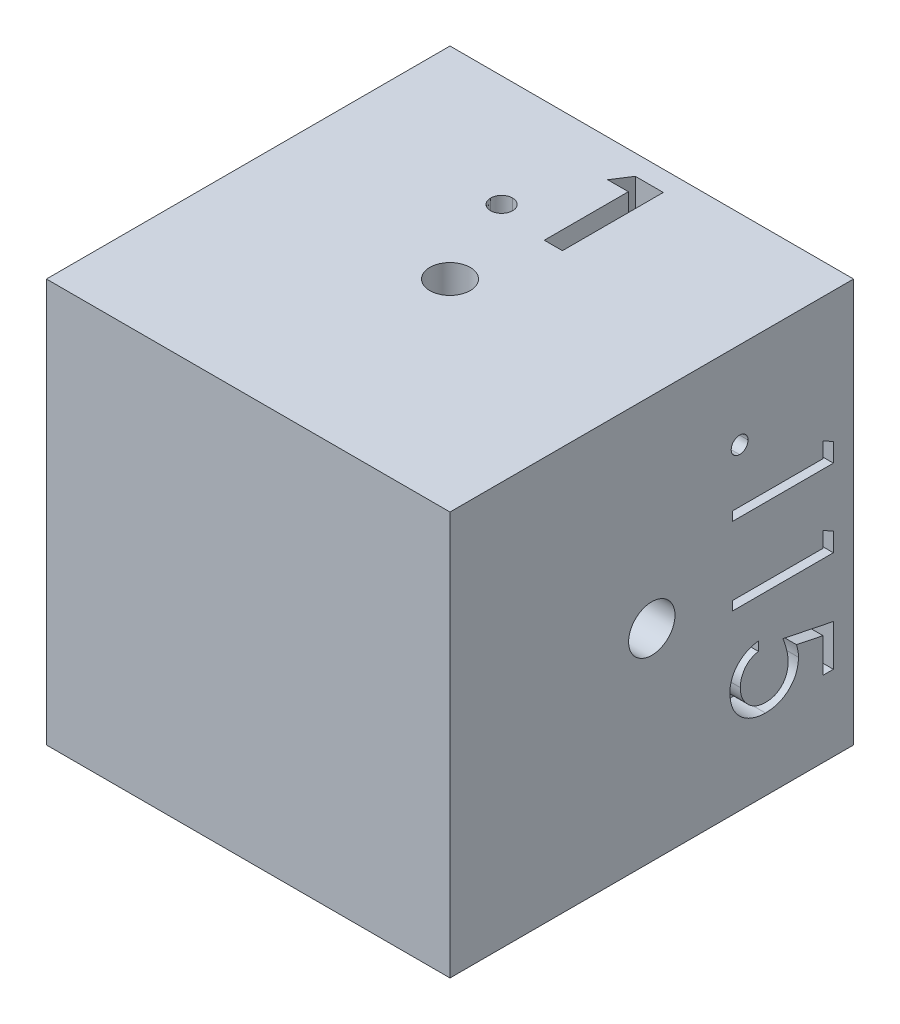
from build123d import *

# Parameters (mm, degrees)
SKETCH1_W           = 25.4
SKETCH1_H           = 25.4
BOSS_EXTRUDE1_DEPTH = 12.7
SKETCH2_R           = 1.27
CUT_EXTRUDE1_DEPTH  = 12.7
SKETCH4_R           = 1.4605
CUT_EXTRUDE2_DEPTH  = 12.7
SKETCH5_R           = 1.524
CUT_EXTRUDE3_DEPTH  = 12.7
SKETCH6_R           = 1.5875
CUT_EXTRUDE4_DEPTH  = 12.7
CUT_EXTRUDE5_DEPTH  = 1.905
CUT_EXTRUDE6_DEPTH  = 1.905
CUT_EXTRUDE7_DEPTH  = 1.905
CUT_EXTRUDE8_DEPTH  = 1.905


with BuildPart() as part:
    # Sketch1 → Boss-Extrude1 (new body, symmetric)
    with BuildSketch(Plane(origin=(0, 0, 0), x_dir=(1, 0, 0), z_dir=(0, 1, 0))):
        Rectangle(SKETCH1_W, SKETCH1_H)
    extrude(amount=BOSS_EXTRUDE1_DEPTH, both=True)

    # Sketch2 → Cut-Extrude1 (cut)
    with BuildSketch(Plane(origin=(0, 12.7, 0), x_dir=(1, 0, 0), z_dir=(0, 1, 0))):
        Circle(SKETCH2_R)
    extrude(amount=-CUT_EXTRUDE1_DEPTH, mode=Mode.SUBTRACT)

    # Sketch4 → Cut-Extrude2 (cut)
    with BuildSketch(Plane(origin=(12.7, 0, 0), x_dir=(0, 0, -1), z_dir=(1, 0, 0))):
        Circle(SKETCH4_R)
    extrude(amount=-CUT_EXTRUDE2_DEPTH, mode=Mode.SUBTRACT)

    # Sketch5 → Cut-Extrude3 (cut)
    with BuildSketch(Plane.XZ.offset(12.7)):
        Circle(SKETCH5_R)
    extrude(amount=-CUT_EXTRUDE3_DEPTH, mode=Mode.SUBTRACT)

    # Sketch6 → Cut-Extrude4 (cut)
    with BuildSketch(Plane(origin=(-12.7, 0, 0), x_dir=(0, 0, -1), z_dir=(1, 0, 0))):
        Circle(SKETCH6_R)
    extrude(amount=CUT_EXTRUDE4_DEPTH, mode=Mode.SUBTRACT)

    # Sketch7 → Cut-Extrude5 (cut)
    with BuildSketch(Plane(origin=(0, 12.7, 0), x_dir=(1, 0, 0), z_dir=(0, 1, 0))):
        with BuildLine():
            add(Edge.make_bspline(
                [(-2.442307692, 6.382564103), (-2.396297595, 6.380041479), (-2.30571166, 6.37507487), (-2.174827334, 6.338009585), (-2.056703477, 6.271416521), (-1.951084965, 6.184557409), (-1.861776611, 6.080054302), (-1.797226553, 5.960881284), (-1.757029613, 5.830501274), (-1.752591842, 5.739630345), (-1.750320513, 5.693120994)],
                knots=[0, 0, 0, 0, 0.000137967, 0.000271634, 0.000403712, 0.000541989, 0.000680103, 0.000813297, 0.000946101, 0.001085336, 0.001085336, 0.001085336, 0.001085336], degree=3))
            add(Edge.make_bspline(
                [(-1.750320513, 5.693120994), (-1.752576963, 5.646604173), (-1.756985662, 5.555718649), (-1.797504712, 5.425084584), (-1.861680153, 5.304932073), (-1.951092131, 5.199309146), (-2.056266074, 5.110813094), (-2.175098922, 5.044834114), (-2.305462327, 5.00566621), (-2.39625371, 5.00097126), (-2.442307692, 4.998589744)],
                knots=[0, 0, 0, 0, 0.000139234, 0.000272039, 0.000406351, 0.00054544, 0.000684529, 0.000816606, 0.000950629, 0.001088597, 0.001088597, 0.001088597, 0.001088597], degree=3))
            add(Edge.make_bspline(
                [(-2.442307692, 4.998589744), (-2.488372587, 5.000951894), (-2.579185482, 5.005608667), (-2.709751529, 5.045164261), (-2.829461693, 5.110372593), (-2.934662062, 5.199416492), (-3.024473492, 5.304558054), (-3.086824366, 5.425463687), (-3.12772084, 5.555669398), (-3.132069269, 5.6465875), (-3.134294872, 5.693120994)],
                knots=[0, 0, 0, 0, 0.000137967, 0.000271991, 0.000405184, 0.000544273, 0.000683362, 0.000817077, 0.000949881, 0.001089116, 0.001089116, 0.001089116, 0.001089116], degree=3))
            add(Edge.make_bspline(
                [(-3.134294872, 5.693120994), (-3.132054586, 5.739647308), (-3.127677469, 5.830551382), (-3.087101733, 5.960497815), (-3.024373564, 6.080430354), (-2.934669552, 6.184449841), (-2.829022037, 6.271853583), (-2.71002464, 6.337683962), (-2.578936276, 6.375132839), (-2.488328754, 6.380061005), (-2.442307692, 6.382564103)],
                knots=[0, 0, 0, 0, 0.000139234, 0.000272039, 0.000404629, 0.000542743, 0.000681021, 0.000814215, 0.000947882, 0.001085849, 0.001085849, 0.001085849, 0.001085849], degree=3))
        make_face()
        Polygon((0.232782452, 11.43), (1.994551282, 11.43), (1.994551282, 5.08), (0.854807692, 5.08), (0.854807692, 10.371666667), (-0.44775641, 10.371666667), align=None)
    extrude(amount=-CUT_EXTRUDE5_DEPTH, mode=Mode.SUBTRACT)

    # Sketch9 → Cut-Extrude6 (cut)
    with BuildSketch(Plane(origin=(12.7, 0, 0), x_dir=(0, 0, -1), z_dir=(1, 0, 0))):
        with BuildLine():
            add(Edge.make_bspline(
                [(6.056923077, 7.245512821), (6.054891267, 7.210127533), (6.050931558, 7.141166644), (6.021829667, 7.041309193), (5.972726399, 6.950057506), (5.905258007, 6.869277712), (5.824709926, 6.802139353), (5.733690044, 6.752471082), (5.633543092, 6.722035242), (5.563587428, 6.718273105), (5.52775641, 6.716346154)],
                knots=[0, 0, 0, 0, 0.000106068, 0.000206712, 0.000309148, 0.00041485, 0.000520551, 0.000621868, 0.000724091, 0.000831425, 0.000831425, 0.000831425, 0.000831425], degree=3))
            add(Edge.make_bspline(
                [(5.52775641, 6.716346154), (5.492786963, 6.718350083), (5.423708683, 6.722308623), (5.324319503, 6.752407893), (5.233239101, 6.802528231), (5.151595984, 6.868819458), (5.083983162, 6.950077164), (5.035317742, 7.041529807), (5.004179507, 7.140927253), (5.000483127, 7.210087249), (4.998589744, 7.245512821)],
                knots=[0, 0, 0, 0, 0.000104802, 0.000207025, 0.000308342, 0.000415026, 0.000520727, 0.000623164, 0.000724168, 0.000830237, 0.000830237, 0.000830237, 0.000830237], degree=3))
            add(Edge.make_bspline(
                [(4.998589744, 7.245512821), (5.000554208, 7.280912884), (5.004411918, 7.350429642), (5.034695939, 7.450199496), (5.084449722, 7.54109856), (5.151471016, 7.62237209), (5.233662038, 7.68811272), (5.323699421, 7.74054204), (5.423995789, 7.768232771), (5.492843512, 7.772510326), (5.52775641, 7.774679487)],
                knots=[0, 0, 0, 0, 0.000106068, 0.000208291, 0.000309608, 0.000415309, 0.000521993, 0.000623923, 0.000725789, 0.000830591, 0.000830591, 0.000830591, 0.000830591], degree=3))
            add(Edge.make_bspline(
                [(5.52775641, 7.774679487), (5.563528859, 7.772581422), (5.633251269, 7.768492182), (5.734309873, 7.740477824), (5.824291021, 7.688508785), (5.905381725, 7.621912749), (5.972261337, 7.541118533), (6.022442049, 7.450413936), (6.050702586, 7.350194375), (6.054821832, 7.280873634), (6.056923077, 7.245512821)],
                knots=[0, 0, 0, 0, 0.000107334, 0.000209201, 0.00031113, 0.000416832, 0.000522533, 0.00062385, 0.000725716, 0.000831784, 0.000831784, 0.000831784, 0.000831784], degree=3))
        make_face()
        Polygon((11.43, 4.471203926), (11.43, 3.297115385), (5.08, 3.297115385), (5.08, 3.866987179), (10.778717949, 3.866987179), (10.778717949, 4.843910256), align=None)
        Polygon((11.43, -0.413411458), (11.43, -1.5875), (5.08, -1.5875), (5.08, -1.017628205), (10.778717949, -1.017628205), (10.778717949, -0.040705128), align=None)
        with BuildLine():
            Line((11.43, -7.9375), (10.778717949, -7.9375))
            Line((10.778717949, -7.9375), (10.778717949, -5.777584135))
            Line((10.778717949, -5.777584135), (9.108535657, -5.435406651))
            add(Edge.make_bspline(
                [(9.108535657, -5.435406651), (9.127096293, -5.502636594), (9.16305459, -5.632883977), (9.202979345, -5.825125439), (9.22704665, -6.007628436), (9.230332885, -6.126056608), (9.231923077, -6.183363381)],
                knots=[0, 0, 0, 0, 0.000209191, 0.000405274, 0.000588611, 0.000760505, 0.000760505, 0.000760505, 0.000760505], degree=3))
            add(Edge.make_bspline(
                [(9.231923077, -6.183363381), (9.230387906, -6.254272207), (9.227369377, -6.393696676), (9.198397587, -6.597696528), (9.152765869, -6.792416436), (9.089122448, -6.97752371), (9.007214214, -7.153417054), (8.906223075, -7.319114197), (8.786847577, -7.475554206), (8.650239492, -7.620669004), (8.499706458, -7.752112957), (8.33838207, -7.868138945), (8.166119588, -7.964635121), (7.983680744, -8.044023974), (7.79137165, -8.107011362), (7.587768837, -8.149049426), (7.374679093, -8.177010413), (7.228984395, -8.18013661), (7.154689503, -8.181730769)],
                knots=[0, 0, 0, 0, 0.000212616, 0.000418057, 0.000616755, 0.000811858, 0.001004205, 0.001197709, 0.001392845, 0.001593525, 0.001794559, 0.001991523, 0.00218859, 0.002385686, 0.002587623, 0.002794449, 0.003008552, 0.003231336, 0.003231336, 0.003231336, 0.003231336], degree=3))
            add(Edge.make_bspline(
                [(7.154689503, -8.181730769), (7.102941978, -8.180524295), (7.000146252, -8.178127652), (6.847485626, -8.165935831), (6.698052212, -8.142475611), (6.551848249, -8.110932885), (6.409069199, -8.070155009), (6.269766997, -8.020254344), (6.133512706, -7.961433762), (6.000297404, -7.895023931), (5.874227905, -7.818200065), (5.753358138, -7.737275088), (5.642136364, -7.647632488), (5.536502247, -7.553612314), (5.440604205, -7.451455087), (5.350338346, -7.344331604), (5.269625633, -7.229727944), (5.195388158, -7.109695939), (5.128918807, -6.984311278), (5.073471495, -6.852302589), (5.024871447, -6.716567806), (4.98534963, -6.57589714), (4.954686413, -6.430563112), (4.933805178, -6.280065254), (4.918612262, -6.125158737), (4.917660336, -6.020157145), (4.917179487, -5.967117388)],
                knots=[0, 0, 0, 0, 0.000155272, 0.000308445, 0.000459024, 0.000608725, 0.000756894, 0.000904154, 0.001052306, 0.00120192, 0.001350264, 0.001494918, 0.001637953, 0.001778454, 0.001918817, 0.002057905, 0.002198383, 0.002338884, 0.00248113, 0.002623604, 0.00276804, 0.002913414, 0.003061605, 0.003213255, 0.003369073, 0.003528123, 0.003528123, 0.003528123, 0.003528123], degree=3))
            add(Edge.make_bspline(
                [(4.917179487, -5.967117388), (4.918432974, -5.903845737), (4.920899063, -5.77936624), (4.946693892, -5.596992107), (4.983645571, -5.421528211), (5.039207691, -5.254363195), (5.108930064, -5.094086683), (5.196489179, -4.942832263), (5.297098586, -4.797626959), (5.41422965, -4.66241728), (5.5434557, -4.537181012), (5.682187687, -4.423352123), (5.830977231, -4.323524869), (5.988557634, -4.237291863), (6.155200039, -4.163842599), (6.331403101, -4.106114027), (6.516280415, -4.059528098), (6.643558707, -4.039818482), (6.708205128, -4.029807692)],
                knots=[0, 0, 0, 0, 0.000189687, 0.000373186, 0.000551585, 0.000726969, 0.000900684, 0.001075027, 0.001250411, 0.001429913, 0.001610725, 0.001789725, 0.001967538, 0.002147431, 0.002327992, 0.002513029, 0.002703073, 0.002899231, 0.002899231, 0.002899231, 0.002899231], degree=3))
            Line((6.708205128, -4.029807692), (6.708205128, -4.599679487))
            add(Edge.make_bspline(
                [(6.708205128, -4.599679487), (6.64764493, -4.613692474), (6.531244866, -4.640626212), (6.367797746, -4.699899793), (6.221595909, -4.771925897), (6.092501332, -4.859521151), (5.979336183, -4.961898746), (5.87761919, -5.077883765), (5.787069571, -5.209128567), (5.711106198, -5.354914487), (5.646416187, -5.50880895), (5.603317623, -5.669852892), (5.573019052, -5.83369212), (5.569985783, -5.944505555), (5.568461538, -6.000190304)],
                knots=[0, 0, 0, 0, 0.000186343, 0.000358162, 0.000520291, 0.000674118, 0.000824546, 0.000976877, 0.001136009, 0.001301598, 0.001469314, 0.001635659, 0.001800867, 0.001967742, 0.001967742, 0.001967742, 0.001967742], degree=3))
            add(Edge.make_bspline(
                [(5.568461538, -6.000190304), (5.569950664, -6.054543482), (5.572882765, -6.161565334), (5.595450687, -6.319065993), (5.630207995, -6.471126493), (5.682223303, -6.616246412), (5.745441578, -6.756965205), (5.826567501, -6.889723331), (5.919930677, -7.018361408), (6.026894849, -7.138881022), (6.144768438, -7.249261166), (6.27082028, -7.346790128), (6.405289416, -7.428028243), (6.54584785, -7.496488697), (6.69403609, -7.548473968), (6.849159651, -7.585559748), (7.011601686, -7.607336726), (7.122398862, -7.610332439), (7.178858173, -7.611858974)],
                knots=[0, 0, 0, 0, 0.000162999, 0.000320947, 0.000476453, 0.000630132, 0.000782676, 0.000938437, 0.001095928, 0.001259031, 0.001421025, 0.001579785, 0.001736204, 0.001891522, 0.002048024, 0.002206299, 0.002369289, 0.002538641, 0.002538641, 0.002538641, 0.002538641], degree=3))
            add(Edge.make_bspline(
                [(7.178858173, -7.611858974), (7.229826301, -7.610856727), (7.329646331, -7.608893846), (7.475041678, -7.587081418), (7.613611912, -7.556525591), (7.744117841, -7.509611018), (7.868470538, -7.45164408), (7.984008401, -7.378101855), (8.093699797, -7.294035516), (8.193088559, -7.195570581), (8.285438896, -7.088198755), (8.364049623, -6.969427574), (8.430213096, -6.841966119), (8.487302962, -6.70728962), (8.528307751, -6.562211228), (8.559092179, -6.409599403), (8.576900097, -6.247807437), (8.579370946, -6.13718918), (8.580641026, -6.080328526)],
                knots=[0, 0, 0, 0, 0.000152777, 0.00029921, 0.000440222, 0.000577814, 0.000714373, 0.000850961, 0.000987851, 0.001128179, 0.001269879, 0.001412057, 0.001554303, 0.001700294, 0.001850038, 0.002005705, 0.002166968, 0.002337539, 0.002337539, 0.002337539, 0.002337539], degree=3))
            add(Edge.make_bspline(
                [(8.580641026, -6.080328526), (8.579623437, -6.030681463), (8.577540275, -5.929046217), (8.56114622, -5.772782201), (8.535925543, -5.609286755), (8.4995745, -5.437925138), (8.454060491, -5.259167622), (8.397219201, -5.072716931), (8.331745202, -4.87856856), (8.280961339, -4.747892805), (8.255, -4.681089744)],
                knots=[0, 0, 0, 0, 0.000148915, 0.000304852, 0.000470905, 0.000645039, 0.00083015, 0.001024118, 0.001229672, 0.001444658, 0.001444658, 0.001444658, 0.001444658], degree=3))
            Line((8.255, -4.681089744), (11.43, -5.332371795))
            Line((11.43, -5.332371795), (11.43, -7.9375))
        make_face()
    extrude(amount=-CUT_EXTRUDE6_DEPTH, mode=Mode.SUBTRACT)

    # Sketch10 → Cut-Extrude7 (cut)
    with BuildSketch(Plane(origin=(0, -12.7, 0), x_dir=(-1, 0, 0), z_dir=(0, -1, 0))):
        with BuildLine():
            add(Edge.make_bspline(
                [(-4.803205128, 6.056923077), (-4.767844315, 6.054821832), (-4.698523574, 6.050702586), (-4.598304012, 6.022442049), (-4.507599415, 5.972261337), (-4.4268052, 5.905381725), (-4.360209164, 5.824291021), (-4.308240125, 5.734309873), (-4.280225766, 5.633251269), (-4.276136526, 5.563528859), (-4.274038462, 5.52775641)],
                knots=[0, 0, 0, 0, 0.000106068, 0.000207934, 0.000309251, 0.000414952, 0.000520654, 0.000622584, 0.00072445, 0.000831784, 0.000831784, 0.000831784, 0.000831784], degree=3))
            add(Edge.make_bspline(
                [(-4.274038462, 5.52775641), (-4.276207623, 5.492843512), (-4.280485177, 5.423995789), (-4.308175909, 5.323699421), (-4.360605229, 5.233662038), (-4.426345859, 5.151471016), (-4.507619388, 5.084449722), (-4.598518453, 5.034695939), (-4.698288307, 5.004411918), (-4.767805065, 5.000554208), (-4.803205128, 4.998589744)],
                knots=[0, 0, 0, 0, 0.000104802, 0.000206668, 0.000308598, 0.000415282, 0.000520984, 0.0006223, 0.000724523, 0.000830591, 0.000830591, 0.000830591, 0.000830591], degree=3))
            add(Edge.make_bspline(
                [(-4.803205128, 4.998589744), (-4.8386307, 5.000483127), (-4.907790695, 5.004179507), (-5.007188142, 5.035317742), (-5.098640785, 5.083983162), (-5.179898491, 5.151595984), (-5.246189718, 5.233239101), (-5.296310055, 5.324319503), (-5.326409325, 5.423708683), (-5.330367866, 5.492786963), (-5.332371795, 5.52775641)],
                knots=[0, 0, 0, 0, 0.000106068, 0.000207073, 0.000309509, 0.000415211, 0.000521895, 0.000623212, 0.000725435, 0.000830237, 0.000830237, 0.000830237, 0.000830237], degree=3))
            add(Edge.make_bspline(
                [(-5.332371795, 5.52775641), (-5.330444843, 5.563587428), (-5.326682707, 5.633543092), (-5.296246866, 5.733690044), (-5.246578596, 5.824709926), (-5.179440237, 5.905258007), (-5.098660443, 5.972726399), (-5.007408756, 6.021829667), (-4.907551304, 6.050931558), (-4.838590416, 6.054891267), (-4.803205128, 6.056923077)],
                knots=[0, 0, 0, 0, 0.000107334, 0.000209557, 0.000310874, 0.000416575, 0.000522277, 0.000624713, 0.000725357, 0.000831425, 0.000831425, 0.000831425, 0.000831425], degree=3))
        make_face()
        Polygon((-2.11030649, 11.43), (-0.936217949, 11.43), (-0.936217949, 5.08), (-1.506089744, 5.08), (-1.506089744, 10.778717949), (-2.483012821, 10.778717949), align=None)
        with BuildLine():
            Line((2.238782051, 9.476153846), (1.668910256, 9.476153846))
            add(Edge.make_bspline(
                [(1.668910256, 9.476153846), (1.672624377, 9.551756743), (1.679918811, 9.700238819), (1.714078707, 9.916726478), (1.762957155, 10.12365447), (1.832065936, 10.319361314), (1.91789304, 10.505577435), (2.020817519, 10.681563178), (2.142726362, 10.846647192), (2.280987151, 10.999299093), (2.43115311, 11.1393394), (2.5931796, 11.260271055), (2.763441292, 11.362447402), (2.941421631, 11.447866226), (3.129128653, 11.511982804), (3.324858981, 11.55955635), (3.529472557, 11.588179149), (3.668882311, 11.591255788), (3.739783654, 11.592820513)],
                knots=[0, 0, 0, 0, 0.000226936, 0.000445697, 0.000656417, 0.000864005, 0.001067188, 0.001270734, 0.001474522, 0.00168168, 0.001887816, 0.002089561, 0.002286989, 0.002482721, 0.002680645, 0.002880876, 0.003086317, 0.003298933, 0.003298933, 0.003298933, 0.003298933], degree=3))
            add(Edge.make_bspline(
                [(3.739783654, 11.592820513), (3.809412445, 11.591190456), (3.946230534, 11.587987453), (4.145914474, 11.560481014), (4.336010423, 11.517399726), (4.516146799, 11.456956043), (4.684886373, 11.375704296), (4.843496754, 11.27810019), (4.993866225, 11.165215639), (5.129224247, 11.032312291), (5.253517476, 10.890430822), (5.360745854, 10.738959912), (5.452572593, 10.58251535), (5.529113098, 10.419904185), (5.585457807, 10.249595319), (5.628235413, 10.074068251), (5.652415149, 9.891506094), (5.656126132, 9.767941343), (5.658012821, 9.705120192)],
                knots=[0, 0, 0, 0, 0.000208804, 0.000410292, 0.000603457, 0.000792922, 0.000978974, 0.001163976, 0.001350969, 0.00154169, 0.001731956, 0.001916203, 0.002097498, 0.002275629, 0.002454231, 0.002634721, 0.00281696, 0.003005431, 0.003005431, 0.003005431, 0.003005431], degree=3))
            add(Edge.make_bspline(
                [(5.658012821, 9.705120192), (5.654940758, 9.616677692), (5.648850543, 9.441344733), (5.59675446, 9.183689197), (5.515390075, 8.934055422), (5.417423442, 8.733146317), (5.318594865, 8.571251264), (5.229536101, 8.437958042), (5.125278516, 8.294438121), (5.004304669, 8.141172094), (4.86911703, 7.976959452), (4.718491105, 7.801899395), (4.551352788, 7.617800613), (4.434043793, 7.49206045), (4.373257212, 7.426905048)],
                knots=[0, 0, 0, 0, 0.0002651, 0.000525547, 0.000785404, 0.001051089, 0.001193761, 0.001354284, 0.001531883, 0.001725783, 0.001939958, 0.002169957, 0.002418529, 0.002685853, 0.002685853, 0.002685853, 0.002685853], degree=3))
            Line((4.373257212, 7.426905048), (2.784485176, 5.731282051))
            Line((2.784485176, 5.731282051), (5.739423077, 5.731282051))
            Line((5.739423077, 5.731282051), (5.739423077, 5.08))
            Line((5.739423077, 5.08), (1.424679487, 5.08))
            Line((1.424679487, 5.08), (3.887339744, 7.70802484))
            add(Edge.make_bspline(
                [(3.887339744, 7.70802484), (3.947298053, 7.770614624), (4.062465693, 7.890836792), (4.22535694, 8.066356162), (4.371659104, 8.229187472), (4.502319231, 8.379023067), (4.614502876, 8.518054626), (4.714056783, 8.641779302), (4.793822927, 8.755633805), (4.880392287, 8.887606061), (4.964237654, 9.04873698), (5.036287214, 9.245648102), (5.080219868, 9.44835326), (5.085490069, 9.585335527), (5.088141026, 9.654238782)],
                knots=[0, 0, 0, 0, 0.000260022, 0.000499448, 0.000718331, 0.000916736, 0.001095736, 0.001254271, 0.001392976, 0.001512588, 0.001727648, 0.001936091, 0.002140165, 0.002346709, 0.002346709, 0.002346709, 0.002346709], degree=3))
            add(Edge.make_bspline(
                [(5.088141026, 9.654238782), (5.086987607, 9.697566462), (5.084714442, 9.782956999), (5.064652619, 9.908153162), (5.034334987, 10.028920753), (4.990891447, 10.145631247), (4.93354779, 10.257111216), (4.863746086, 10.363496359), (4.783209829, 10.466346338), (4.690043954, 10.562781608), (4.58769734, 10.651103223), (4.479576344, 10.729342636), (4.365185441, 10.794727879), (4.245006933, 10.848328224), (4.119375867, 10.890374987), (3.988049258, 10.919509839), (3.851389972, 10.937802345), (3.758074915, 10.940277343), (3.710526843, 10.941538462)],
                knots=[0, 0, 0, 0, 0.000129903, 0.000256015, 0.000379422, 0.000502993, 0.000628718, 0.000754676, 0.000884205, 0.001020051, 0.00115623, 0.001289314, 0.001419795, 0.001550759, 0.001683503, 0.001816508, 0.001953776, 0.002096386, 0.002096386, 0.002096386, 0.002096386], degree=3))
            add(Edge.make_bspline(
                [(3.710526843, 10.941538462), (3.660868332, 10.940241189), (3.563347216, 10.937693559), (3.420165542, 10.91987244), (3.283575631, 10.889127844), (3.153233893, 10.847078735), (3.028919787, 10.79363251), (2.911237879, 10.727063202), (2.800452351, 10.647627436), (2.696354945, 10.557565284), (2.600444583, 10.457294065), (2.516176679, 10.345515989), (2.442545682, 10.224271964), (2.378303216, 10.093889136), (2.326132178, 9.953184421), (2.286266605, 9.802657299), (2.254721898, 9.642961365), (2.244183582, 9.532679853), (2.238782051, 9.476153846)],
                knots=[0, 0, 0, 0, 0.000148964, 0.000292541, 0.00043203, 0.000568399, 0.000702856, 0.000837284, 0.000973177, 0.00111115, 0.001249715, 0.001388623, 0.001530208, 0.001674706, 0.001824033, 0.001979555, 0.002141464, 0.002311717, 0.002311717, 0.002311717, 0.002311717], degree=3))
        make_face()
    extrude(amount=-CUT_EXTRUDE7_DEPTH, mode=Mode.SUBTRACT)

    # Sketch11 → Cut-Extrude8 (cut)
    with BuildSketch(Plane.ZY.offset(12.7)):
        with BuildLine():
            add(Edge.make_bspline(
                [(-6.056923077, -7.245512821), (-6.054821832, -7.210152007), (-6.050702586, -7.140831266), (-6.022442049, -7.040611705), (-5.972261337, -6.949907108), (-5.905381725, -6.869112892), (-5.824291021, -6.802516856), (-5.734309873, -6.750547817), (-5.633251269, -6.722533459), (-5.563528859, -6.718444219), (-5.52775641, -6.716346154)],
                knots=[0, 0, 0, 0, 0.000106068, 0.000207934, 0.000309251, 0.000414952, 0.000520654, 0.000622584, 0.00072445, 0.000831784, 0.000831784, 0.000831784, 0.000831784], degree=3))
            add(Edge.make_bspline(
                [(-5.52775641, -6.716346154), (-5.492837518, -6.718508634), (-5.423977976, -6.722773013), (-5.323768368, -6.750560457), (-5.233684021, -6.802453769), (-5.152783388, -6.86953661), (-5.084288404, -6.949423933), (-5.034772975, -7.040895483), (-5.004391738, -7.140577835), (-5.000547399, -7.210106628), (-4.998589744, -7.245512821)],
                knots=[0, 0, 0, 0, 0.000104802, 0.000206668, 0.000308598, 0.000414299, 0.000520817, 0.000622133, 0.000724356, 0.000830424, 0.000830424, 0.000830424, 0.000830424], degree=3))
            add(Edge.make_bspline(
                [(-4.998589744, -7.245512821), (-5.000476335, -7.280944512), (-5.004159455, -7.350116456), (-5.03539395, -7.449427168), (-5.083815908, -7.541456241), (-5.15290808, -7.621322804), (-5.233265553, -7.68894926), (-5.324388771, -7.738540294), (-5.423690789, -7.768737026), (-5.492780949, -7.772682283), (-5.52775641, -7.774679487)],
                knots=[0, 0, 0, 0, 0.000106068, 0.000207073, 0.000309509, 0.000416027, 0.000521728, 0.000623045, 0.000725268, 0.00083007, 0.00083007, 0.00083007, 0.00083007], degree=3))
            add(Edge.make_bspline(
                [(-5.52775641, -7.774679487), (-5.563587428, -7.772752536), (-5.633543092, -7.768990399), (-5.733690044, -7.738554559), (-5.824709926, -7.688886288), (-5.905258007, -7.621747929), (-5.972726399, -7.540968135), (-6.021829667, -7.449716448), (-6.050931558, -7.349858997), (-6.054891267, -7.280898108), (-6.056923077, -7.245512821)],
                knots=[0, 0, 0, 0, 0.000107334, 0.000209557, 0.000310874, 0.000416575, 0.000522277, 0.000624713, 0.000725357, 0.000831425, 0.000831425, 0.000831425, 0.000831425], degree=3))
        make_face()
        Polygon((-11.43, -4.471203926), (-11.43, -3.297115385), (-5.08, -3.297115385), (-5.08, -3.866987179), (-10.778717949, -3.866987179), (-10.778717949, -4.843910256), align=None)
        with BuildLine():
            Line((-9.476153846, -0.122115385), (-9.476153846, -0.691987179))
            add(Edge.make_bspline(
                [(-9.476153846, -0.691987179), (-9.551756743, -0.688273059), (-9.700238819, -0.680978625), (-9.916726478, -0.646818729), (-10.12365447, -0.59794028), (-10.319361314, -0.5288315), (-10.505577435, -0.443004396), (-10.681563178, -0.340079917), (-10.846647192, -0.218171074), (-10.999299093, -0.079910285), (-11.1393394, 0.070255674), (-11.260271055, 0.232282164), (-11.362447402, 0.402543857), (-11.447866226, 0.580524195), (-11.511982804, 0.768231217), (-11.55955635, 0.963961545), (-11.588179149, 1.168575121), (-11.591255788, 1.307984875), (-11.592820513, 1.378886218)],
                knots=[0, 0, 0, 0, 0.000226936, 0.000445697, 0.000656417, 0.000864005, 0.001067188, 0.001270734, 0.001474522, 0.00168168, 0.001887816, 0.002089561, 0.002286989, 0.002482721, 0.002680645, 0.002880876, 0.003086317, 0.003298933, 0.003298933, 0.003298933, 0.003298933], degree=3))
            add(Edge.make_bspline(
                [(-11.592820513, 1.378886218), (-11.591203684, 1.44851991), (-11.588026674, 1.585347626), (-11.560333104, 1.784962248), (-11.517895176, 1.975442471), (-11.455008853, 2.154629584), (-11.376100274, 2.324362551), (-11.277967117, 2.482539795), (-11.165252714, 2.632986209), (-11.032300548, 2.768318143), (-10.890440251, 2.892636851), (-10.738934647, 2.999792061), (-10.582273187, 3.09207497), (-10.419232118, 3.167605649), (-10.249280498, 3.224861263), (-10.074047712, 3.267282186), (-9.891511455, 3.291532277), (-9.76794315, 3.295233605), (-9.705120192, 3.297115385)],
                knots=[0, 0, 0, 0, 0.000208804, 0.000410292, 0.000603457, 0.000793336, 0.000978844, 0.001163845, 0.001350838, 0.001541559, 0.001731825, 0.001916073, 0.002097368, 0.002276653, 0.00245405, 0.00263454, 0.002816779, 0.003005251, 0.003005251, 0.003005251, 0.003005251], degree=3))
            add(Edge.make_bspline(
                [(-9.705120192, 3.297115385), (-9.616677731, 3.294043274), (-9.441344847, 3.287952963), (-9.183688752, 3.235857588), (-8.934057102, 3.15449051), (-8.733141149, 3.056532559), (-8.571261422, 2.957684549), (-8.437911847, 2.868697234), (-8.29436799, 2.763930415), (-8.140048859, 2.644279172), (-7.976975392, 2.507682942), (-7.801820454, 2.357690477), (-7.617822779, 2.190428169), (-7.492068016, 2.073137079), (-7.426905048, 2.012359776)],
                knots=[0, 0, 0, 0, 0.0002651, 0.000525547, 0.000785404, 0.001051089, 0.001193761, 0.001354284, 0.001531883, 0.001726786, 0.00193998, 0.00216998, 0.002418551, 0.002685875, 0.002685875, 0.002685875, 0.002685875], degree=3))
            Line((-7.426905048, 2.012359776), (-5.731282051, 0.42358774))
            Line((-5.731282051, 0.42358774), (-5.731282051, 3.378525641))
            Line((-5.731282051, 3.378525641), (-5.08, 3.378525641))
            Line((-5.08, 3.378525641), (-5.08, -0.936217949))
            Line((-5.08, -0.936217949), (-7.70802484, 1.526442308))
            add(Edge.make_bspline(
                [(-7.70802484, 1.526442308), (-7.770614624, 1.586400617), (-7.890836792, 1.701568257), (-8.066356162, 1.864459504), (-8.229187472, 2.010761668), (-8.379023067, 2.141421795), (-8.518054626, 2.253605441), (-8.641779302, 2.353159347), (-8.755633805, 2.432925491), (-8.887606061, 2.519494852), (-9.04873698, 2.603340218), (-9.245648102, 2.675389778), (-9.44835326, 2.719322432), (-9.585335527, 2.724592633), (-9.654238782, 2.72724359)],
                knots=[0, 0, 0, 0, 0.000260022, 0.000499448, 0.000718331, 0.000916736, 0.001095736, 0.001254271, 0.001392976, 0.001512588, 0.001727648, 0.001936091, 0.002140165, 0.002346709, 0.002346709, 0.002346709, 0.002346709], degree=3))
            add(Edge.make_bspline(
                [(-9.654238782, 2.72724359), (-9.697566462, 2.726090172), (-9.782956999, 2.723817006), (-9.908153162, 2.703755183), (-10.028920753, 2.673437551), (-10.145631247, 2.629994011), (-10.257111216, 2.572650354), (-10.363496359, 2.502848651), (-10.466346338, 2.422312393), (-10.562781608, 2.329146518), (-10.651103223, 2.226799904), (-10.729342636, 2.118678908), (-10.794727879, 2.004288005), (-10.848328224, 1.884109497), (-10.890374987, 1.758478431), (-10.919509839, 1.627151822), (-10.937802345, 1.490492536), (-10.940277343, 1.397177479), (-10.941538462, 1.349629407)],
                knots=[0, 0, 0, 0, 0.000129903, 0.000256015, 0.000379422, 0.000502993, 0.000628718, 0.000754676, 0.000884205, 0.001020051, 0.00115623, 0.001289314, 0.001419795, 0.001550759, 0.001683503, 0.001816508, 0.001953776, 0.002096386, 0.002096386, 0.002096386, 0.002096386], degree=3))
            add(Edge.make_bspline(
                [(-10.941538462, 1.349629407), (-10.940292377, 1.299958432), (-10.937845273, 1.202412839), (-10.919309685, 1.059498305), (-10.891209726, 0.922222662), (-10.846580858, 0.792634185), (-10.793849631, 0.667926718), (-10.726860291, 0.550762567), (-10.64901719, 0.43919645), (-10.558754939, 0.335063413), (-10.457338776, 0.239956808), (-10.345571163, 0.155218197), (-10.224256737, 0.081665093), (-10.093893398, 0.017401064), (-9.953183212, -0.03476392), (-9.802657642, -0.07463121), (-9.642961272, -0.106175436), (-9.532679822, -0.11671382), (-9.476153846, -0.122115385)],
                knots=[0, 0, 0, 0, 0.000148964, 0.000292541, 0.000431757, 0.000568523, 0.00070298, 0.000837408, 0.000972567, 0.00111054, 0.00125003, 0.001388938, 0.001530523, 0.001675021, 0.001824348, 0.00197987, 0.002141779, 0.002312032, 0.002312032, 0.002312032, 0.002312032], degree=3))
        make_face()
        with BuildLine():
            Line((-11.43, 7.9375), (-10.778717949, 7.9375))
            Line((-10.778717949, 7.9375), (-10.778717949, 5.777584135))
            Line((-10.778717949, 5.777584135), (-9.108535657, 5.435406651))
            add(Edge.make_bspline(
                [(-9.108535657, 5.435406651), (-9.127096293, 5.502636594), (-9.16305459, 5.632883977), (-9.202979345, 5.825125439), (-9.22704665, 6.007628436), (-9.230332885, 6.126056608), (-9.231923077, 6.183363381)],
                knots=[0, 0, 0, 0, 0.000209191, 0.000405274, 0.000588611, 0.000760505, 0.000760505, 0.000760505, 0.000760505], degree=3))
            add(Edge.make_bspline(
                [(-9.231923077, 6.183363381), (-9.230438994, 6.254285468), (-9.227520915, 6.393736011), (-9.19783709, 6.597451822), (-9.154842487, 6.792899988), (-9.088601161, 6.977194736), (-9.007708689, 7.153251793), (-8.905822853, 7.318047593), (-8.786871391, 7.473895052), (-8.651466928, 7.619717032), (-8.500898232, 7.751385186), (-8.338337281, 7.865800472), (-8.167331427, 7.965663792), (-7.983872644, 8.04354822), (-7.791421027, 8.107109511), (-7.587755032, 8.149021985), (-7.374682759, 8.177017702), (-7.228985633, 8.180139072), (-7.154689503, 8.181730769)],
                knots=[0, 0, 0, 0, 0.000212616, 0.000418057, 0.000616466, 0.000811987, 0.001004334, 0.001196752, 0.001391888, 0.001591699, 0.001792733, 0.001990734, 0.002187324, 0.002385586, 0.002587523, 0.00279435, 0.003008452, 0.003231237, 0.003231237, 0.003231237, 0.003231237], degree=3))
            add(Edge.make_bspline(
                [(-7.154689503, 8.181730769), (-7.10294237, 8.180523046), (-7.00014742, 8.17812392), (-6.847481058, 8.165950418), (-6.698068982, 8.14242205), (-6.552185113, 8.111216122), (-6.409692819, 8.069557751), (-6.269794294, 8.020830714), (-6.134021415, 7.960266231), (-6.001774529, 7.893123737), (-5.874567157, 7.818776079), (-5.755449327, 7.735173789), (-5.641702743, 7.648306193), (-5.536705506, 7.553387307), (-5.440050348, 7.451496308), (-5.35125943, 7.343200126), (-5.268739224, 7.229481026), (-5.19586375, 7.108547942), (-5.128802086, 6.98310411), (-5.073786606, 6.851335669), (-5.024600341, 6.716242712), (-4.98539449, 6.575880716), (-4.954673996, 6.430567658), (-4.933808621, 6.280063993), (-4.91861137, 6.125159063), (-4.917660037, 6.020157255), (-4.917179487, 5.967117388)],
                knots=[0, 0, 0, 0, 0.000155272, 0.000308445, 0.000459024, 0.000608725, 0.000755671, 0.000904129, 0.001052789, 0.001201268, 0.001348962, 0.001494336, 0.001637585, 0.001778086, 0.001918449, 0.002058517, 0.00219796, 0.002339545, 0.002481792, 0.002624265, 0.002767503, 0.002912878, 0.003061068, 0.003212718, 0.003368536, 0.003527586, 0.003527586, 0.003527586, 0.003527586], degree=3))
            add(Edge.make_bspline(
                [(-4.917179487, 5.967117388), (-4.918436235, 5.903847273), (-4.920908739, 5.779370797), (-4.946657084, 5.59697477), (-4.983778515, 5.421590828), (-5.038775926, 5.253970642), (-5.11079112, 5.094813284), (-5.196356063, 4.941839655), (-5.298219819, 4.796945797), (-5.415450674, 4.661122306), (-5.544262684, 4.53627041), (-5.682710362, 4.423053791), (-5.830970026, 4.323515477), (-5.988559581, 4.2372944), (-6.155199503, 4.1638419), (-6.331403249, 4.106114221), (-6.516280376, 4.059528047), (-6.643558694, 4.039818464), (-6.708205128, 4.029807692)],
                knots=[0, 0, 0, 0, 0.000189687, 0.000373186, 0.000551585, 0.000726969, 0.0009012, 0.001074916, 0.001252072, 0.001431573, 0.001612385, 0.001789596, 0.001967408, 0.002147301, 0.002327863, 0.002512899, 0.002702944, 0.002899102, 0.002899102, 0.002899102, 0.002899102], degree=3))
            Line((-6.708205128, 4.029807692), (-6.708205128, 4.599679487))
            add(Edge.make_bspline(
                [(-6.708205128, 4.599679487), (-6.647644403, 4.613692526), (-6.531243325, 4.640626366), (-6.367803221, 4.699899246), (-6.222106682, 4.771666884), (-6.093262895, 4.858995598), (-5.978913403, 4.960220759), (-5.878091713, 5.077889776), (-5.787022196, 5.209060965), (-5.710980939, 5.354897566), (-5.646926434, 5.509053909), (-5.601215036, 5.669478673), (-5.573544944, 5.833863034), (-5.570162384, 5.944539215), (-5.568461538, 6.000190304)],
                knots=[0, 0, 0, 0, 0.000186343, 0.000358162, 0.000520291, 0.000672351, 0.000823728, 0.000977018, 0.001136149, 0.001301739, 0.001469455, 0.001636145, 0.001801142, 0.001968016, 0.001968016, 0.001968016, 0.001968016], degree=3))
            add(Edge.make_bspline(
                [(-5.568461538, 6.000190304), (-5.569963124, 6.054538871), (-5.572919757, 6.161551644), (-5.595308966, 6.319118438), (-5.63069666, 6.470798627), (-5.680272793, 6.616861465), (-5.74585911, 6.756589227), (-5.82642812, 6.889784353), (-5.9199697, 7.018344324), (-6.026884311, 7.138885635), (-6.144771192, 7.24925996), (-6.27081956, 7.346790443), (-6.405289606, 7.428028159), (-6.545847799, 7.49648872), (-6.694036104, 7.548473962), (-6.849159647, 7.58555975), (-7.011601687, 7.607336726), (-7.122398863, 7.610332438), (-7.178858173, 7.611858974)],
                knots=[0, 0, 0, 0, 0.000162999, 0.000320947, 0.000476453, 0.000629716, 0.000782794, 0.000938555, 0.001096046, 0.00125915, 0.001421143, 0.001579903, 0.001736322, 0.001891641, 0.002048142, 0.002206417, 0.002369407, 0.00253876, 0.00253876, 0.00253876, 0.00253876], degree=3))
            add(Edge.make_bspline(
                [(-7.178858173, 7.611858974), (-7.22980163, 7.610700603), (-7.329095693, 7.608442819), (-7.474874732, 7.58889733), (-7.613030381, 7.556246898), (-7.744163776, 7.509759316), (-7.867855654, 7.451741327), (-7.983833432, 7.378897983), (-8.093187605, 7.294331018), (-8.193104031, 7.195601003), (-8.28546746, 7.088203183), (-8.363919339, 6.969379036), (-8.430636277, 6.842300723), (-8.485299015, 6.70673275), (-8.528842072, 6.562508128), (-8.558935271, 6.409549178), (-8.576942587, 6.247821038), (-8.579385371, 6.137193798), (-8.580641026, 6.080328526)],
                knots=[0, 0, 0, 0, 0.000152777, 0.000297778, 0.000440319, 0.000577911, 0.00071447, 0.000849305, 0.000987981, 0.001128309, 0.001270008, 0.001412186, 0.001554432, 0.00169994, 0.001850046, 0.002005713, 0.002166975, 0.002337547, 0.002337547, 0.002337547, 0.002337547], degree=3))
            add(Edge.make_bspline(
                [(-8.580641026, 6.080328526), (-8.579587667, 6.031108898), (-8.57741275, 5.929482853), (-8.561398963, 5.773594296), (-8.535564814, 5.609779313), (-8.500029765, 5.438665871), (-8.453527669, 5.259740092), (-8.397802789, 5.073379565), (-8.331178592, 4.879192453), (-8.280864432, 4.748350295), (-8.255, 4.681089744)],
                knots=[0, 0, 0, 0, 0.000147644, 0.000304847, 0.000469643, 0.000645023, 0.000828901, 0.001024087, 0.001228438, 0.001444613, 0.001444613, 0.001444613, 0.001444613], degree=3))
            Line((-8.255, 4.681089744), (-11.43, 5.332371795))
            Line((-11.43, 5.332371795), (-11.43, 7.9375))
        make_face()
    extrude(amount=-CUT_EXTRUDE8_DEPTH, mode=Mode.SUBTRACT)


solid = part.part
